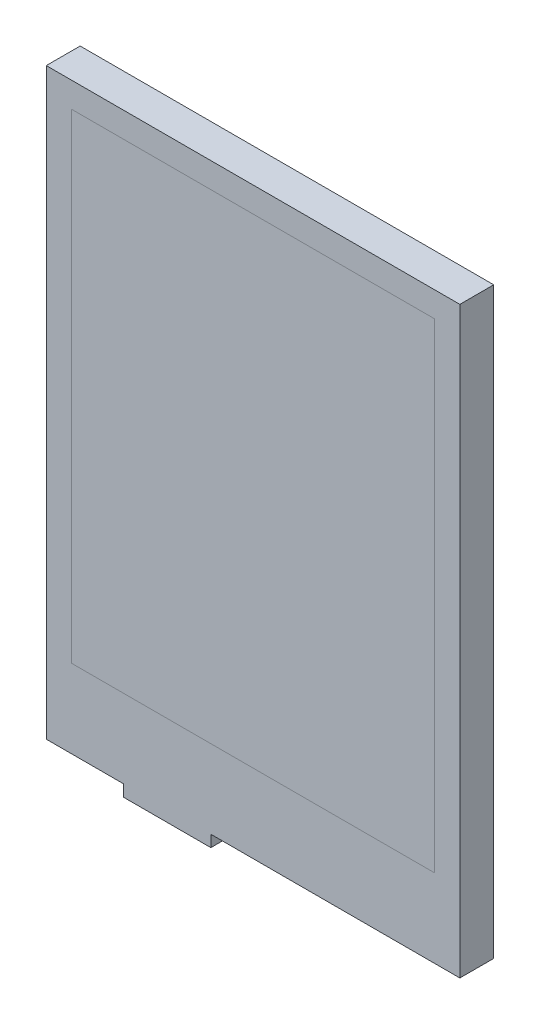
from build123d import *

# Parameters (mm, degrees)
MAIN_FEATURES_SKETCH_W   = 42.72
MAIN_FEATURES_SKETCH_H   = 60.26
MAIN_FEATURES_SKETCH_W_2 = 37.52
MAIN_FEATURES_SKETCH_H_2 = 49.56
MAIN_FEATURES_SKETCH_W_3 = 9
MAIN_FEATURES_SKETCH_H_3 = 1.2
BOSS_EXTRUDE1_DEPTH      = 3.5
SKETCH1_3_W              = 37.52
SKETCH1_3_H              = 49.56
SKETCH1_3_W_2            = 3.9
SKETCH1_3_H_2            = 9.5
BOSS_EXTRUDE2_DEPTH      = 3.5
MAIN_FEATURES_SKETCH_4_W = 3.9
MAIN_FEATURES_SKETCH_4_H = 9.5
CUT_EXTRUDE1_DEPTH       = 0.3
MAIN_FEATURES_SKETCH_5_W = 3.9
MAIN_FEATURES_SKETCH_5_H = 9.5
BOSS_EXTRUDE3_DEPTH      = 0.3


with BuildPart() as part:
    # main_features_sketch → Boss-Extrude1 (new body)
    with BuildSketch(Plane.XY):
        with Locations((0, -2.75)):
            Rectangle(MAIN_FEATURES_SKETCH_W, MAIN_FEATURES_SKETCH_H)
        Rectangle(MAIN_FEATURES_SKETCH_W_2, MAIN_FEATURES_SKETCH_H_2, mode=Mode.SUBTRACT)
        with Locations((-8.86, -33.48)):
            Rectangle(MAIN_FEATURES_SKETCH_W_3, MAIN_FEATURES_SKETCH_H_3)
    extrude(amount=BOSS_EXTRUDE1_DEPTH)


with BuildPart() as body_2:
    # Sketch1_3 → Boss-Extrude2 (new body)
    with BuildSketch(Plane.XY):
        Rectangle(SKETCH1_3_W, SKETCH1_3_H)
        with Locations((-15.05, -4.73)):
            Rectangle(SKETCH1_3_W_2, SKETCH1_3_H_2)
    extrude(amount=BOSS_EXTRUDE2_DEPTH)

    # main_features_sketch_4 → Cut-Extrude1 (cut)
    with BuildSketch(Plane.XY):
        with Locations((-15.05, -4.73)):
            Rectangle(MAIN_FEATURES_SKETCH_4_W, MAIN_FEATURES_SKETCH_4_H)
    extrude(amount=CUT_EXTRUDE1_DEPTH, mode=Mode.SUBTRACT)


with BuildPart() as body_3:
    # main_features_sketch_5 → Boss-Extrude3 (new body)
    with BuildSketch(Plane.XY):
        with Locations((-15.05, -4.73)):
            Rectangle(MAIN_FEATURES_SKETCH_5_W, MAIN_FEATURES_SKETCH_5_H)
    extrude(amount=BOSS_EXTRUDE3_DEPTH)


solid = Compound([part.part, body_2.part, body_3.part])
